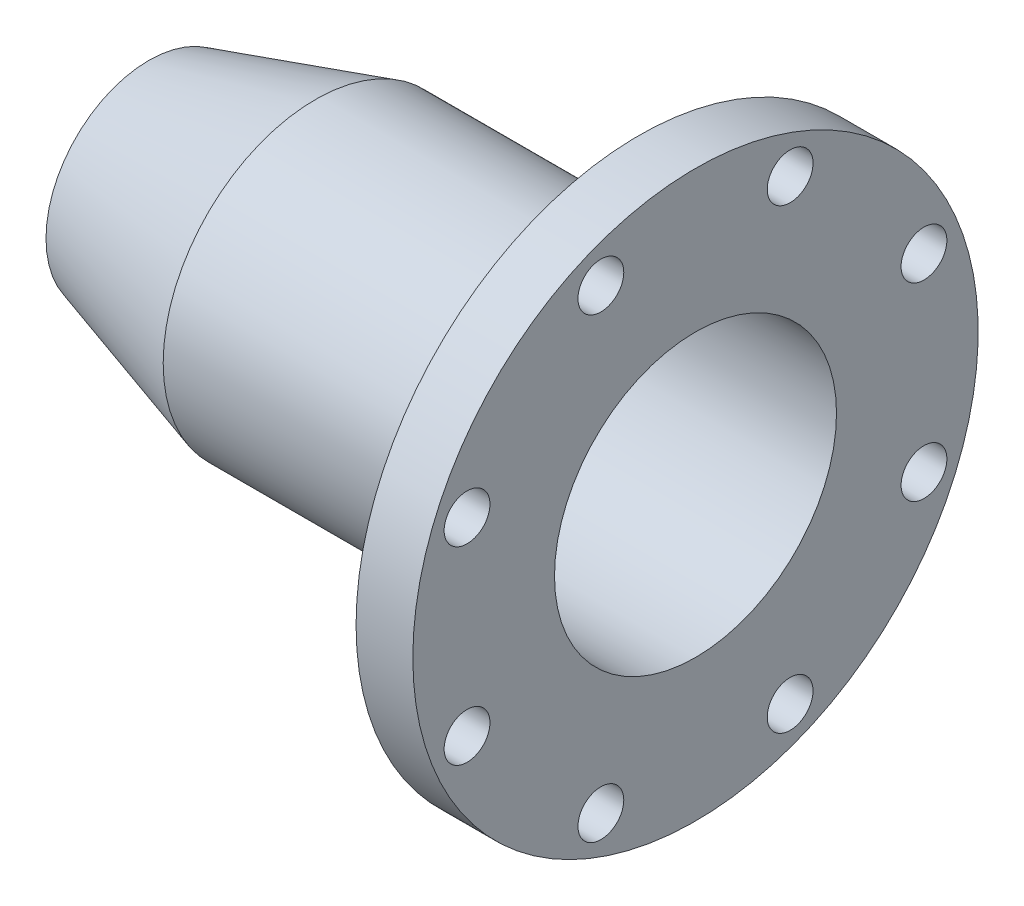
from build123d import *

# Parameters (mm, degrees)
SKETCH1_W                    = 27.69
SKETCH1_H                    = 63.625
F_1_16_0_88_DIAMETER_HOLE1_D = 22.352
CIRPATTERN1_COUNT            = 8


with BuildPart() as part:
    # Sketch1 → Revolve1 (revolve)
    with BuildSketch(Plane.XY):
        Polygon((239.01, 68.795), (266.7, 68.795), (266.7, 74.295), (239.01, 74.295), (81.28, 74.295), (0, 50.18683312), (0, 44.45), (82.078476138, 68.795), align=None)
        with Locations((252.855, 106.1075)):
            Rectangle(SKETCH1_W, SKETCH1_H)
    revolve(axis=Axis((0, 0, 0), (1, 0, 0)))

    # 1/16 (0.88) Diameter Hole1 (through all)
    with Locations(Plane(origin=(266.7, 111.466065597, 46.170756115), x_dir=(0, 0, 1), z_dir=(1, 0, 0))):
        with Locations((0, 0)):
            f_1_16_0_88_diameter_hole1 = Hole(F_1_16_0_88_DIAMETER_HOLE1_D / 2)

    # CirPattern1: 1/16 (0.88) Diameter Hole1 ×8 about axis
    cirpattern1_axis = Axis((0, 0, 0), (1, 0, 0))
    for i in range(1, CIRPATTERN1_COUNT):
        add(f_1_16_0_88_diameter_hole1.rotate(cirpattern1_axis, i * 360 / CIRPATTERN1_COUNT), mode=Mode.SUBTRACT)


solid = part.part
